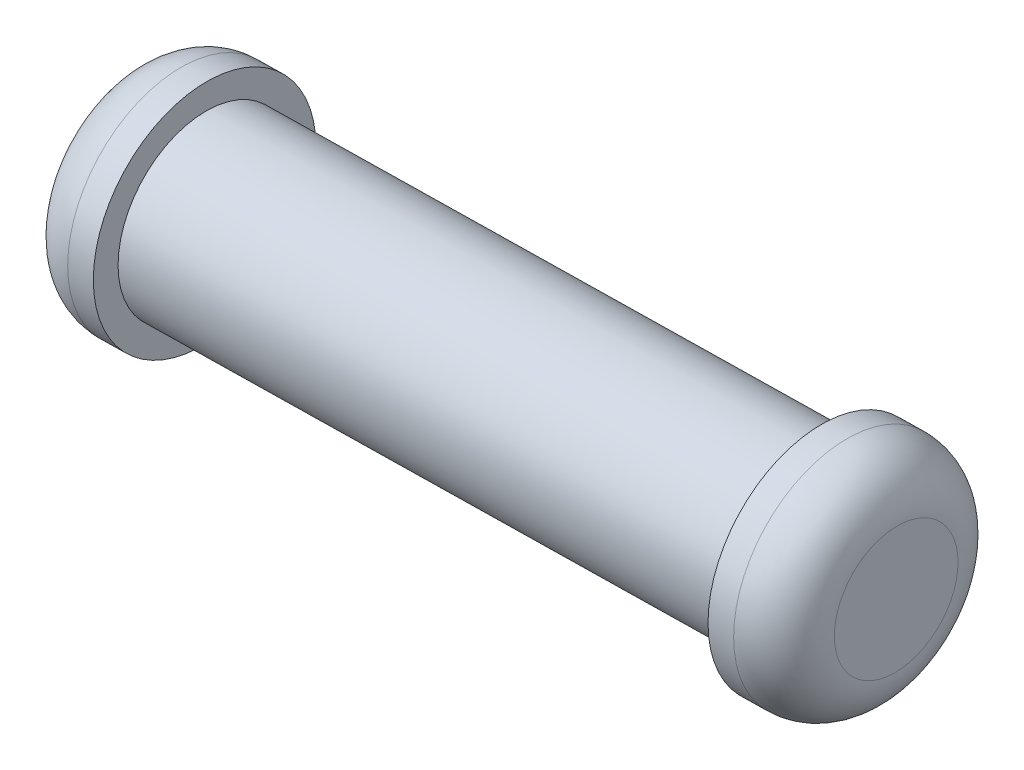
from build123d import *

# Parameters (mm, degrees)
SKETCH1_R           = 1.75
BOSS_EXTRUDE1_DEPTH = 12
SKETCH2_R           = 2.25
BOSS_EXTRUDE2_DEPTH = 1.5
SKETCH3_R           = 2.25
BOSS_EXTRUDE3_DEPTH = 1.5
FILLET1_R           = 1


with BuildPart() as part:
    # Sketch1 → Boss-Extrude1 (new body)
    with BuildSketch(Plane(origin=(-50.041144534, 0, 0.866108158), x_dir=(0.017305329, 0, 0.999850252), z_dir=(-0.999850252, 0, 0.017305329))):
        with Locations((-1.293587728, 26.734731136)):
            Circle(SKETCH1_R)
    extrude(amount=-BOSS_EXTRUDE1_DEPTH)

    # Sketch2 → Boss-Extrude2 (add)
    with BuildSketch(Plane(origin=(-50.041144534, 0, 0.866108158), x_dir=(0.017305329, 0, 0.999850252), z_dir=(-0.999850252, 0, 0.017305329))):
        with Locations((-1.293587728, 26.734731136)):
            Circle(SKETCH2_R)
    extrude(amount=BOSS_EXTRUDE2_DEPTH)

    # Sketch3 → Boss-Extrude3 (add)
    with BuildSketch(Plane(origin=(-38.042941515, 0, 0.658444213), x_dir=(-0.017305329, 0, -0.999850252), z_dir=(0.999850252, 0, -0.017305329))):
        with Locations((1.293587728, 26.734731136)):
            Circle(SKETCH3_R)
    extrude(amount=BOSS_EXTRUDE3_DEPTH)

    # Fillet1
    fillet1_edges = [part.edges().sort_by_distance(p)[0] for p in [
        (-51.602242862, 26.734731136, -2.65099093),
        (-36.526615108, 26.734731136, 1.58875527),
    ]]
    fillet(fillet1_edges, radius=FILLET1_R)


solid = part.part
